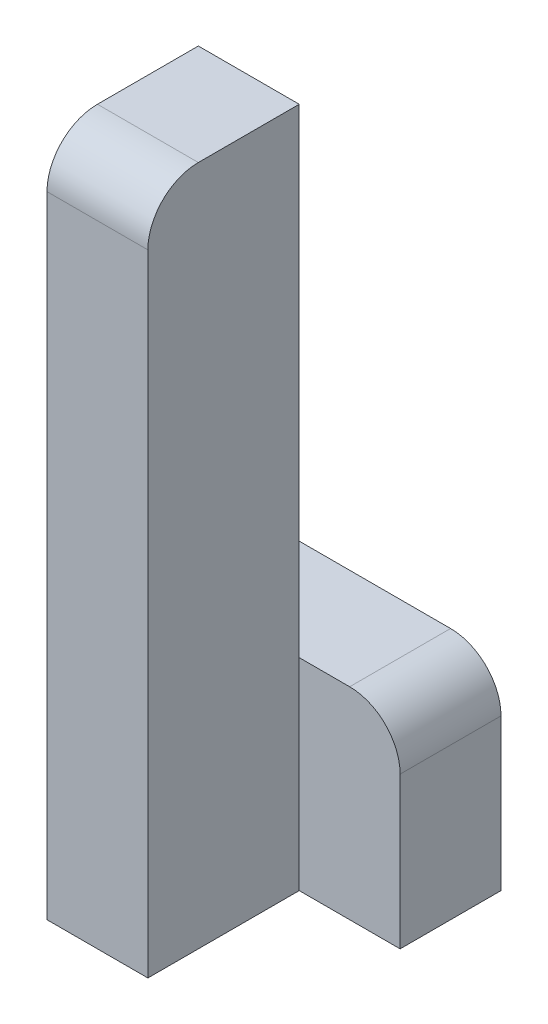
from build123d import *

# Parameters (mm, degrees)
SKETCH1_W           = 20
SKETCH1_H           = 135
BOSS_EXTRUDE1_DEPTH = 30
SKETCH2_W           = 40
SKETCH2_H           = 40
BOSS_EXTRUDE2_DEPTH = 20
FILLET1_R           = 10


with BuildPart() as part:
    # Sketch1 → Boss-Extrude1 (new body)
    with BuildSketch(Plane.XY):
        with Locations((-20, -67.5)):
            Rectangle(SKETCH1_W, SKETCH1_H)
    extrude(amount=BOSS_EXTRUDE1_DEPTH)

    # Sketch2 → Boss-Extrude2 (add)
    with BuildSketch(Plane.XY):
        with Locations((-10, -115)):
            Rectangle(SKETCH2_W, SKETCH2_H)
    extrude(amount=-BOSS_EXTRUDE2_DEPTH)

    # Fillet1
    fillet1_edges = [part.edges().sort_by_distance(p)[0] for p in [
        (10, -95, -10),
        (-20, 0, 30),
    ]]
    fillet(fillet1_edges, radius=FILLET1_R)


solid = part.part
